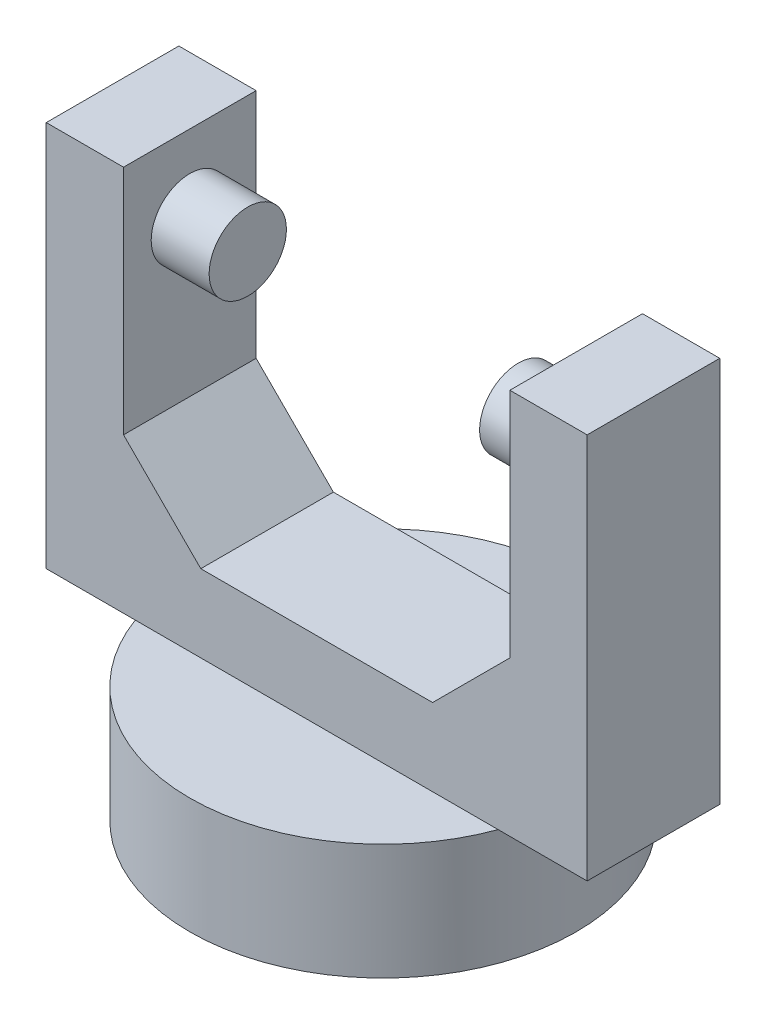
from build123d import *

# Parameters (mm, degrees)
SKETCH1_R           = 12.5
BOSS_EXTRUDE1_DEPTH = 7.5
SKETCH2_W           = 35
SKETCH2_H           = 8.580767914
BOSS_EXTRUDE2_DEPTH = 25
SKETCH3_W           = 25
SKETCH3_H           = 8.580767914
CUT_EXTRUDE1_DEPTH  = 20
SKETCH4_R           = 2.5
BOSS_EXTRUDE3_DEPTH = 3.75
SKETCH5_R           = 2.5
BOSS_EXTRUDE4_DEPTH = 3.75
CHAMFER1_SIZE       = 5
CHAMFER2_SIZE       = 5


with BuildPart() as part:
    # Sketch1 → Boss-Extrude1 (new body)
    with BuildSketch(Plane(origin=(0, 0, 0), x_dir=(1, 0, 0), z_dir=(0, 1, 0))):
        Circle(SKETCH1_R)
    extrude(amount=BOSS_EXTRUDE1_DEPTH)

    # Sketch2 → Boss-Extrude2 (add)
    with BuildSketch(Plane(origin=(0, 7.5, 0), x_dir=(1, 0, 0), z_dir=(0, 1, 0))):
        Rectangle(SKETCH2_W, SKETCH2_H)
    extrude(amount=BOSS_EXTRUDE2_DEPTH)

    # Sketch3 → Cut-Extrude1 (cut)
    with BuildSketch(Plane(origin=(0, 32.5, 0), x_dir=(1, 0, 0), z_dir=(0, 1, 0))):
        Rectangle(SKETCH3_W, SKETCH3_H)
    extrude(amount=-CUT_EXTRUDE1_DEPTH, mode=Mode.SUBTRACT)

    # Sketch4 → Boss-Extrude3 (add)
    with BuildSketch(Plane(origin=(-12.5, 0, 0), x_dir=(0, 0, -1), z_dir=(1, 0, 0))):
        with Locations((0, 27.5)):
            Circle(SKETCH4_R)
    extrude(amount=BOSS_EXTRUDE3_DEPTH)

    # Sketch5 → Boss-Extrude4 (add)
    with BuildSketch(Plane.ZY.offset(-12.5)):
        with Locations((0, 27.5)):
            Circle(SKETCH5_R)
    extrude(amount=BOSS_EXTRUDE4_DEPTH)

    # Chamfer1
    chamfer1_edges = [part.edges().sort_by_distance(p)[0] for p in [
        (-12.5, 12.5, 0),
    ]]
    chamfer(chamfer1_edges, length=CHAMFER1_SIZE)

    # Chamfer2
    chamfer2_edges = [part.edges().sort_by_distance(p)[0] for p in [
        (12.5, 12.5, 0),
    ]]
    chamfer(chamfer2_edges, length=CHAMFER2_SIZE)


solid = part.part
